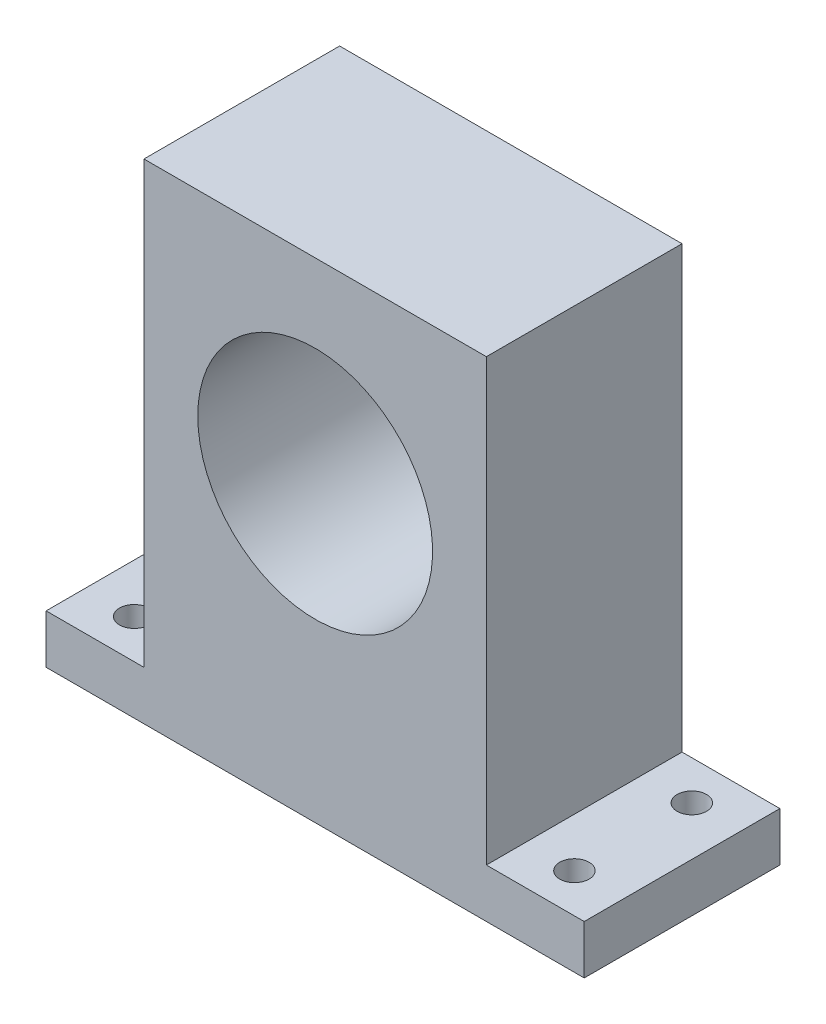
from build123d import *

# Parameters (mm, degrees)
SKETCH_1_W          = 35
SKETCH_1_H          = 50
EXTRUDE_1_DEPTH     = 20
SKETCH_2_W          = 20
SKETCH_2_H          = 5
EXTRUDE_2_DEPTH     = 10
SKETCH_3_W          = 20
SKETCH_3_H          = 5
EXTRUDE_3_DEPTH     = 10
SKETCH_4_R          = 12
CUT_EXTRUDE_1_DEPTH = 20
SKETCH_5_R          = 1.5
CUT_EXTRUDE_2_DEPTH = 5
SKETCH_6_R          = 1.5
CUT_EXTRUDE_3_DEPTH = 5
SKETCH_7_R          = 1.5
CUT_EXTRUDE_4_DEPTH = 5
SKETCH_8_R          = 1.5
CUT_EXTRUDE_5_DEPTH = 5


with BuildPart() as part:
    # Эскиз1 → Бобышка-Вытянуть1 (new body)
    with BuildSketch(Plane.XY):
        Rectangle(SKETCH_1_W, SKETCH_1_H)
    extrude(amount=EXTRUDE_1_DEPTH)

    # Эскиз2 → Бобышка-Вытянуть2 (add)
    with BuildSketch(Plane(origin=(17.5, 0, 0), x_dir=(0, 0, -1), z_dir=(1, 0, 0))):
        with Locations((-10, -22.5)):
            Rectangle(SKETCH_2_W, SKETCH_2_H)
    extrude(amount=EXTRUDE_2_DEPTH)

    # Эскиз3 → Бобышка-Вытянуть3 (add)
    with BuildSketch(Plane.ZY.offset(17.5)):
        with Locations((10, -22.5)):
            Rectangle(SKETCH_3_W, SKETCH_3_H)
    extrude(amount=EXTRUDE_3_DEPTH)

    # Эскиз4 → Вырез-Вытянуть1 (cut)
    with BuildSketch(Plane(origin=(0, 0, 0), x_dir=(-1, 0, 0), z_dir=(0, 0, -1))):
        with Locations((0, 5)):
            Circle(SKETCH_4_R)
    extrude(amount=-CUT_EXTRUDE_1_DEPTH, mode=Mode.SUBTRACT)

    # Эскиз5 → Вырез-Вытянуть2 (cut)
    with BuildSketch(Plane(origin=(0, -20, 0), x_dir=(1, 0, 0), z_dir=(0, 1, 0))):
        with Locations((-22.5, -4)):
            Circle(SKETCH_5_R)
    extrude(amount=-CUT_EXTRUDE_2_DEPTH, mode=Mode.SUBTRACT)

    # Эскиз6 → Вырез-Вытянуть3 (cut)
    with BuildSketch(Plane(origin=(0, -20, 0), x_dir=(1, 0, 0), z_dir=(0, 1, 0))):
        with Locations((-22.5, -16)):
            Circle(SKETCH_6_R)
    extrude(amount=-CUT_EXTRUDE_3_DEPTH, mode=Mode.SUBTRACT)

    # Эскиз7 → Вырез-Вытянуть4 (cut)
    with BuildSketch(Plane(origin=(0, -20, 0), x_dir=(1, 0, 0), z_dir=(0, 1, 0))):
        with Locations((22.5, -4)):
            Circle(SKETCH_7_R)
    extrude(amount=-CUT_EXTRUDE_4_DEPTH, mode=Mode.SUBTRACT)

    # Эскиз8 → Вырез-Вытянуть5 (cut)
    with BuildSketch(Plane(origin=(0, -20, 0), x_dir=(1, 0, 0), z_dir=(0, 1, 0))):
        with Locations((22.5, -16)):
            Circle(SKETCH_8_R)
    extrude(amount=-CUT_EXTRUDE_5_DEPTH, mode=Mode.SUBTRACT)


solid = part.part
